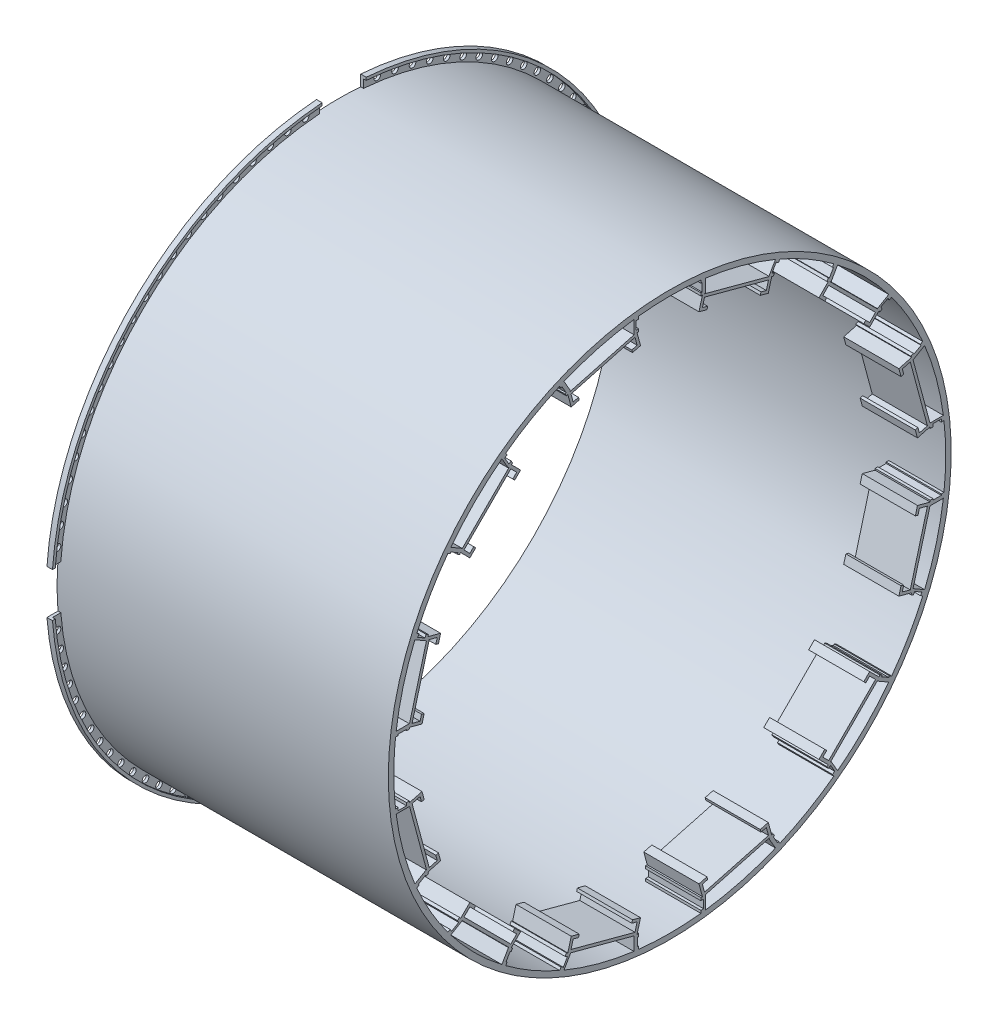
from build123d import *
from build123d.topology import SkipClean

# Parameters (mm, degrees)
KES_EKSTR_ZYON1_REACH       = 1306.531
IZIM4_R                     = 6
KES_EKSTR_ZYON2_DEPTH       = 600
Y_KSEKLIK_EKSTR_ZYON1_START = -20
Y_KSEKLIK_EKSTR_ZYON1_DEPTH = 100
Y_KSEKLIK_EKSTR_ZYON2_START = -20
Y_KSEKLIK_EKSTR_ZYON2_DEPTH = 100
DAIRESEL_O_ALTMA8_COUNT     = 12
DAIRESEL_O_ALTMA9_COUNT     = 12


with BuildPart() as part:
    # izim1 → D_nd_r1 (revolve)
    with BuildSketch(Plane.XY, mode=Mode.PRIVATE) as d_nd_r1_sk:
        Polygon((0, 0), (0, 30), (10, 30), (10, 25), (5, 25), (5, 10), (600, 10), (600, 0), align=None)
    revolve(d_nd_r1_sk.sketch.rotate(Axis((0, -500, 0), (1, 0, 0)), 90), axis=Axis((0, -500, 0), (1, 0, 0)))

    # Kes-Ekstr_zyon1: up to this face of the body (flat: up to its plane)
    kes_ekstr_zyon1_end = Plane(part.part.faces().sort_by_distance((600, -500, -508.557502166))[0])
    # izim3 → Kes-Ekstr_zyon1 (cut, up to the picked face)
    with BuildSketch(Plane.ZY, mode=Mode.PRIVATE) as kes_ekstr_zyon1_sk1:
        with BuildLine():
            Line((-40, 28.488410469), (-40, 8.428952755))
            ThreePointArc((-40, 8.428952755), (0, 10), (40, 8.428952755))
            Line((40, 8.428952755), (40, 28.488410469))
            ThreePointArc((40, 28.488410469), (0, 30), (-40, 28.488410469))
        make_face()
    kes_ekstr_zyon1_tool1 = split(extrude(kes_ekstr_zyon1_sk1.sketch, amount=-KES_EKSTR_ZYON1_REACH, mode=Mode.PRIVATE), bisect_by=kes_ekstr_zyon1_end, keep=Keep.BOTH, mode=Mode.PRIVATE)
    # izim3 → Kes-Ekstr_zyon1 (cut, up to the picked face)
    with BuildSketch(Plane.ZY, mode=Mode.PRIVATE) as kes_ekstr_zyon1_sk2:
        with BuildLine():
            ThreePointArc((-508.428952755, -540), (-510, -500), (-508.428952755, -460))
            Line((-508.428952755, -460), (-528.488410469, -460))
            ThreePointArc((-528.488410469, -460), (-530, -500), (-528.488410469, -540))
            Line((-528.488410469, -540), (-508.428952755, -540))
        make_face()
    kes_ekstr_zyon1_tool2 = split(extrude(kes_ekstr_zyon1_sk2.sketch, amount=-KES_EKSTR_ZYON1_REACH, mode=Mode.PRIVATE), bisect_by=kes_ekstr_zyon1_end, keep=Keep.BOTH, mode=Mode.PRIVATE)
    # izim3 → Kes-Ekstr_zyon1 (cut, up to the picked face)
    with BuildSketch(Plane.ZY, mode=Mode.PRIVATE) as kes_ekstr_zyon1_sk3:
        with BuildLine():
            ThreePointArc((40, -1008.428952755), (0, -1010), (-40, -1008.428952755))
            Line((-40, -1008.428952755), (-40, -1028.488410469))
            ThreePointArc((-40, -1028.488410469), (0, -1030), (40, -1028.488410469))
            Line((40, -1028.488410469), (40, -1008.428952755))
        make_face()
    kes_ekstr_zyon1_tool3 = split(extrude(kes_ekstr_zyon1_sk3.sketch, amount=-KES_EKSTR_ZYON1_REACH, mode=Mode.PRIVATE), bisect_by=kes_ekstr_zyon1_end, keep=Keep.BOTH, mode=Mode.PRIVATE)
    # izim3 → Kes-Ekstr_zyon1 (cut, up to the picked face)
    with BuildSketch(Plane.ZY, mode=Mode.PRIVATE) as kes_ekstr_zyon1_sk4:
        with BuildLine():
            Line((528.488410469, -460), (508.428952755, -460))
            ThreePointArc((508.428952755, -460), (509.607086835, -479.984579761), (510, -500))
            ThreePointArc((510, -500), (509.607086835, -520.015420239), (508.428952755, -540))
            Line((508.428952755, -540), (528.488410469, -540))
            ThreePointArc((528.488410469, -540), (529.621967798, -520.014275548), (530, -500))
            ThreePointArc((530, -500), (529.621967798, -479.985724452), (528.488410469, -460))
        make_face()
    kes_ekstr_zyon1_tool4 = split(extrude(kes_ekstr_zyon1_sk4.sketch, amount=-KES_EKSTR_ZYON1_REACH, mode=Mode.PRIVATE), bisect_by=kes_ekstr_zyon1_end, keep=Keep.BOTH, mode=Mode.PRIVATE)
    add(kes_ekstr_zyon1_tool1.solids().sort_by(Axis((0, 19.486126, 0), (1, 0, 0)))[0], mode=Mode.SUBTRACT)
    add(kes_ekstr_zyon1_tool2.solids().sort_by(Axis((0, -500, -519.486126), (1, 0, 0)))[0], mode=Mode.SUBTRACT)
    add(kes_ekstr_zyon1_tool3.solids().sort_by(Axis((0, -1019.486126, 0), (1, 0, 0)))[0], mode=Mode.SUBTRACT)
    add(kes_ekstr_zyon1_tool4.solids().sort_by(Axis((0, -500, 519.486126), (1, 0, 0)))[0], mode=Mode.SUBTRACT)

    # izim4 → Kes-Ekstr_zyon2 (cut)
    with SkipClean():  # the faces are left unmerged after this step: merging them gives an invalid solid
        with BuildSketch(Plane.ZY):
            with Locations((0, 18.458681612)):
                Circle(IZIM4_R)
            with Locations((32.554289973, 17.435621835)):
                Circle(IZIM4_R)
            with Locations((64.980103036, 14.370480052)):
                Circle(IZIM4_R)
            with Locations((97.149469319, 9.275352977)):
                Circle(IZIM4_R)
            with Locations((128.93543103, 2.170348751)):
                Circle(IZIM4_R)
            with Locations((160.212543499, -6.916492423)):
                Circle(IZIM4_R)
            with Locations((190.857370254, -17.949308932)):
                Circle(IZIM4_R)
            with Locations((220.748970163, -30.884559291)):
                Circle(IZIM4_R)
            with Locations((249.769374737, -45.671193976)):
                Circle(IZIM4_R)
            with Locations((277.804053697, -62.250856896)):
                Circle(IZIM4_R)
            with Locations((304.742366975, -80.558115694)):
                Circle(IZIM4_R)
            with Locations((330.478001353, -100.520719986)):
                Circle(IZIM4_R)
            with Locations((354.909390041, -122.05988649)):
                Circle(IZIM4_R)
            with Locations((377.94011351, -145.090609959)):
                Circle(IZIM4_R)
            with Locations((399.479280014, -169.521998647)):
                Circle(IZIM4_R)
            with Locations((419.441884306, -195.257633025)):
                Circle(IZIM4_R)
            with Locations((437.749143104, -222.195946303)):
                Circle(IZIM4_R)
            with Locations((454.328806024, -250.230625263)):
                Circle(IZIM4_R)
            with Locations((469.115440709, -279.251029837)):
                Circle(IZIM4_R)
            with Locations((482.050691068, -309.142629746)):
                Circle(IZIM4_R)
            with Locations((493.083507577, -339.787456501)):
                Circle(IZIM4_R)
            with Locations((502.170348751, -371.06456897)):
                Circle(IZIM4_R)
            with Locations((509.275352977, -402.850530681)):
                Circle(IZIM4_R)
            with Locations((514.370480052, -435.019896964)):
                Circle(IZIM4_R)
            with Locations((517.435621835, -467.445710027)):
                Circle(IZIM4_R)
            with Locations((518.458681612, -500)):
                Circle(IZIM4_R)
            with Locations((517.435621835, -532.554289973)):
                Circle(IZIM4_R)
            with Locations((514.370480052, -564.980103036)):
                Circle(IZIM4_R)
            with Locations((509.275352977, -597.149469319)):
                Circle(IZIM4_R)
            with Locations((502.170348751, -628.93543103)):
                Circle(IZIM4_R)
            with Locations((493.083507577, -660.212543499)):
                Circle(IZIM4_R)
            with Locations((482.050691068, -690.857370254)):
                Circle(IZIM4_R)
            with Locations((469.115440709, -720.748970163)):
                Circle(IZIM4_R)
            with Locations((454.328806024, -749.769374737)):
                Circle(IZIM4_R)
            with Locations((437.749143104, -777.804053697)):
                Circle(IZIM4_R)
            with Locations((419.441884306, -804.742366975)):
                Circle(IZIM4_R)
            with Locations((399.479280014, -830.478001353)):
                Circle(IZIM4_R)
            with Locations((377.94011351, -854.909390041)):
                Circle(IZIM4_R)
            with Locations((354.909390041, -877.94011351)):
                Circle(IZIM4_R)
            with Locations((330.478001353, -899.479280014)):
                Circle(IZIM4_R)
            with Locations((304.742366975, -919.441884305)):
                Circle(IZIM4_R)
            with Locations((277.804053697, -937.749143104)):
                Circle(IZIM4_R)
            with Locations((249.769374737, -954.328806024)):
                Circle(IZIM4_R)
            with Locations((220.748970163, -969.115440709)):
                Circle(IZIM4_R)
            with Locations((190.857370254, -982.050691068)):
                Circle(IZIM4_R)
            with Locations((160.212543499, -993.083507577)):
                Circle(IZIM4_R)
            with Locations((128.93543103, -1002.170348751)):
                Circle(IZIM4_R)
            with Locations((97.149469319, -1009.275352977)):
                Circle(IZIM4_R)
            with Locations((64.980103036, -1014.370480052)):
                Circle(IZIM4_R)
            with Locations((32.554289973, -1017.435621835)):
                Circle(IZIM4_R)
            with Locations((0, -1018.458681612)):
                Circle(IZIM4_R)
            with Locations((-32.554289973, -1017.435621835)):
                Circle(IZIM4_R)
            with Locations((-64.980103036, -1014.370480052)):
                Circle(IZIM4_R)
            with Locations((-97.149469319, -1009.275352977)):
                Circle(IZIM4_R)
            with Locations((-128.93543103, -1002.170348751)):
                Circle(IZIM4_R)
            with Locations((-160.212543499, -993.083507577)):
                Circle(IZIM4_R)
            with Locations((-190.857370254, -982.050691068)):
                Circle(IZIM4_R)
            with Locations((-220.748970163, -969.115440709)):
                Circle(IZIM4_R)
            with Locations((-249.769374737, -954.328806024)):
                Circle(IZIM4_R)
            with Locations((-277.804053697, -937.749143104)):
                Circle(IZIM4_R)
            with Locations((-304.742366975, -919.441884306)):
                Circle(IZIM4_R)
            with Locations((-330.478001353, -899.479280014)):
                Circle(IZIM4_R)
            with Locations((-354.909390041, -877.94011351)):
                Circle(IZIM4_R)
            with Locations((-377.94011351, -854.909390041)):
                Circle(IZIM4_R)
            with Locations((-399.479280014, -830.478001353)):
                Circle(IZIM4_R)
            with Locations((-419.441884305, -804.742366975)):
                Circle(IZIM4_R)
            with Locations((-437.749143104, -777.804053697)):
                Circle(IZIM4_R)
            with Locations((-454.328806023, -749.769374737)):
                Circle(IZIM4_R)
            with Locations((-469.115440709, -720.748970163)):
                Circle(IZIM4_R)
            with Locations((-482.050691068, -690.857370254)):
                Circle(IZIM4_R)
            with Locations((-493.083507577, -660.212543499)):
                Circle(IZIM4_R)
            with Locations((-502.170348751, -628.93543103)):
                Circle(IZIM4_R)
            with Locations((-509.275352977, -597.149469319)):
                Circle(IZIM4_R)
            with Locations((-514.370480052, -564.980103036)):
                Circle(IZIM4_R)
            with Locations((-517.435621835, -532.554289973)):
                Circle(IZIM4_R)
            with Locations((-518.458681612, -500)):
                Circle(IZIM4_R)
            with Locations((-517.435621835, -467.445710027)):
                Circle(IZIM4_R)
            with Locations((-514.370480052, -435.019896964)):
                Circle(IZIM4_R)
            with Locations((-509.275352977, -402.850530681)):
                Circle(IZIM4_R)
            with Locations((-502.170348751, -371.06456897)):
                Circle(IZIM4_R)
            with Locations((-493.083507577, -339.787456501)):
                Circle(IZIM4_R)
            with Locations((-482.050691068, -309.142629746)):
                Circle(IZIM4_R)
            with Locations((-469.115440709, -279.251029837)):
                Circle(IZIM4_R)
            with Locations((-454.328806024, -250.230625263)):
                Circle(IZIM4_R)
            with Locations((-437.749143104, -222.195946303)):
                Circle(IZIM4_R)
            with Locations((-419.441884306, -195.257633025)):
                Circle(IZIM4_R)
            with Locations((-399.479280014, -169.521998647)):
                Circle(IZIM4_R)
            with Locations((-377.94011351, -145.090609959)):
                Circle(IZIM4_R)
            with Locations((-354.909390041, -122.05988649)):
                Circle(IZIM4_R)
            with Locations((-330.478001353, -100.520719986)):
                Circle(IZIM4_R)
            with Locations((-304.742366975, -80.558115695)):
                Circle(IZIM4_R)
            with Locations((-277.804053697, -62.250856896)):
                Circle(IZIM4_R)
            with Locations((-249.769374737, -45.671193976)):
                Circle(IZIM4_R)
            with Locations((-220.748970163, -30.884559291)):
                Circle(IZIM4_R)
            with Locations((-190.857370254, -17.949308932)):
                Circle(IZIM4_R)
            with Locations((-160.212543499, -6.916492423)):
                Circle(IZIM4_R)
            with Locations((-128.93543103, 2.170348751)):
                Circle(IZIM4_R)
            with Locations((-97.149469319, 9.275352977)):
                Circle(IZIM4_R)
            with Locations((-64.980103036, 14.370480052)):
                Circle(IZIM4_R)
            with Locations((-32.554289973, 17.435621835)):
                Circle(IZIM4_R)
        extrude(amount=-KES_EKSTR_ZYON2_DEPTH, mode=Mode.SUBTRACT)

    # izim5 → Y_kseklik-Ekstr_zyon1 (add)
    with SkipClean():  # the faces are left unmerged after this step: merging them gives an invalid solid
        with BuildSketch(Plane(origin=(620, 0, 0), x_dir=(0, 0, -1), z_dir=(1, 0, 0)).offset(Y_KSEKLIK_EKSTR_ZYON1_START)):
            Polygon((-65, -3), (-65, -28), (-56.35, -28), (-56.35, -23), (-61.35, -23), (-61.35, -8), (-56.35, -8), (-56.35, -3), align=None)
        y_kseklik_ekstr_zyon1 = extrude(amount=-Y_KSEKLIK_EKSTR_ZYON1_DEPTH)

    # izim5_3 → Y_kseklik-Ekstr_zyon2 (add)
    with SkipClean():  # the faces are left unmerged after this step: merging them gives an invalid solid
        with BuildSketch(Plane(origin=(620, 0, 0), x_dir=(0, 0, -1), z_dir=(1, 0, 0)).offset(Y_KSEKLIK_EKSTR_ZYON2_START)):
            Polygon((56.35, -28), (59.179067101, -28), (59.449075622, -26.992314481), (63.209809178, -28), (65, -28), (65, -3), (56.35, -3), (56.35, -8), (58.65, -8), (58.65, -23), (56.35, -23), align=None)
            Polygon((68.761582114, -50.193116683), (59.102323851, -47.604926232), (62.984609528, -33.116038838), (178.895708683, -64.17432425), (175.013423006, -78.663211644), (165.354164743, -76.075021193), (164.060069518, -80.904650325), (178.548956912, -84.786936001), (185.01943304, -60.638790344), (63.209809178, -28), (59.449075622, -26.992314481), (59.179067101, -28), (52.978599494, -51.140460138), (67.467486889, -55.022745814), align=None)
        y_kseklik_ekstr_zyon2 = extrude(amount=-Y_KSEKLIK_EKSTR_ZYON2_DEPTH)

    # Dairesel _o_altma8: Y_kseklik-Ekstr_zyon2 ×12 about axis
    with SkipClean():  # the faces are left unmerged after this step: merging them gives an invalid solid
        dairesel_o_altma8_axis = Axis((0, -500, 0), (1, 0, 0))
        for i in range(1, DAIRESEL_O_ALTMA8_COUNT):
            add(y_kseklik_ekstr_zyon2.rotate(dairesel_o_altma8_axis, i * 360 / DAIRESEL_O_ALTMA8_COUNT))

    # Dairesel _o_altma9: Y_kseklik-Ekstr_zyon1 ×12 about axis
    with SkipClean():  # the faces are left unmerged after this step: merging them gives an invalid solid
        dairesel_o_altma9_axis = Axis((0, -500, 0), (1, 0, 0))
        for i in range(1, DAIRESEL_O_ALTMA9_COUNT):
            add(y_kseklik_ekstr_zyon1.rotate(dairesel_o_altma9_axis, i * 360 / DAIRESEL_O_ALTMA9_COUNT))


solid = part.part
